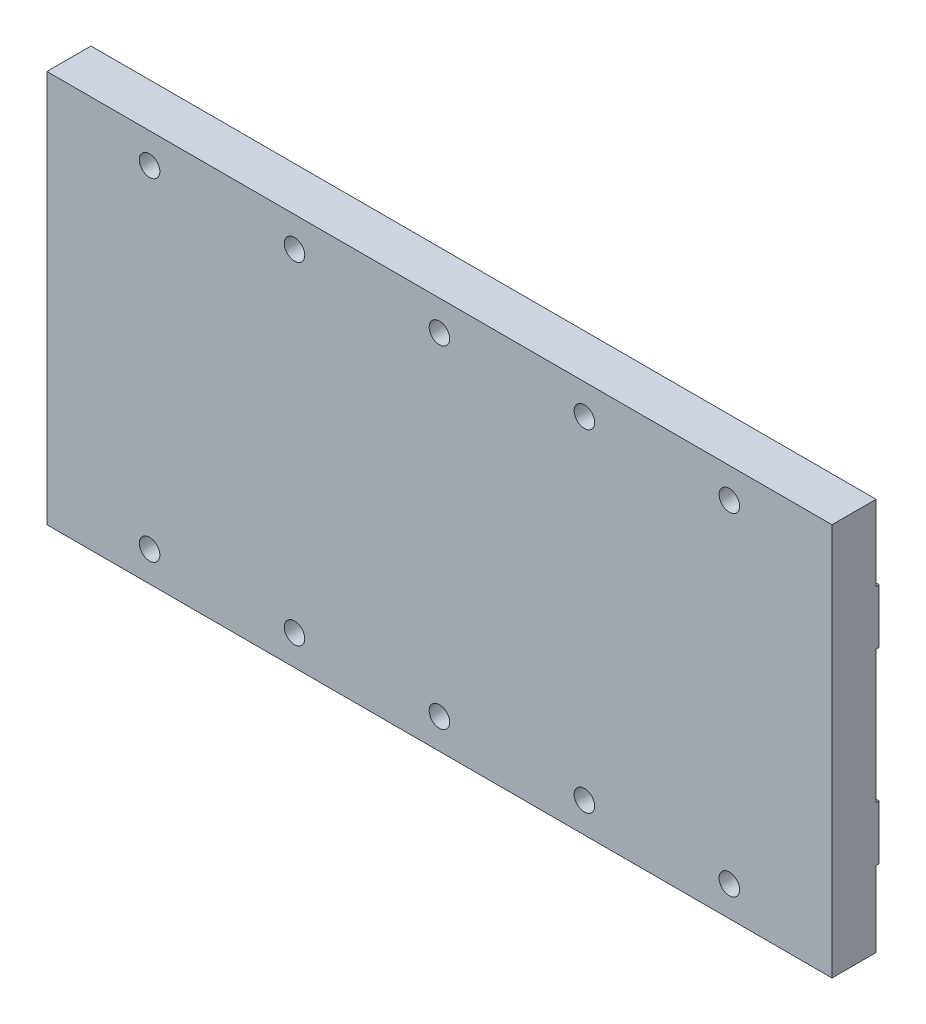
from build123d import *

# Parameters (mm, degrees)
ESQUISSE1_W             = 130
ESQUISSE1_H             = 65
ESQUISSE1_R             = 1.3
BOSS_EXTRU_1_DEPTH      = 7.8
ESQUISSE2_W             = 130
ESQUISSE2_H             = 12.5
ESQUISSE2_H_2           = 22
ENL_V_MAT_EXTRU_1_DEPTH = 0.5
D_GAGEMENT_M3_D         = 3.4
D_GAGEMENT_M3_DEPTH     = 6.978536948
D_GAGEMENT_M3_TIP       = 1.021463052


with BuildPart() as part:
    # Esquisse1 → Boss.-Extru.1 (new body)
    with BuildSketch(Plane.XY):
        with Locations((65, 32.5)):
            Rectangle(ESQUISSE1_W, ESQUISSE1_H)
        with Locations((113, 5)):
            Circle(ESQUISSE1_R, mode=Mode.SUBTRACT)
        with Locations((89, 5)):
            Circle(ESQUISSE1_R, mode=Mode.SUBTRACT)
        with Locations((65, 5)):
            Circle(ESQUISSE1_R, mode=Mode.SUBTRACT)
        with Locations((41, 5)):
            Circle(ESQUISSE1_R, mode=Mode.SUBTRACT)
        with Locations((17, 5)):
            Circle(ESQUISSE1_R, mode=Mode.SUBTRACT)
        with Locations((113, 60)):
            Circle(ESQUISSE1_R, mode=Mode.SUBTRACT)
        with Locations((89, 60)):
            Circle(ESQUISSE1_R, mode=Mode.SUBTRACT)
        with Locations((65, 60)):
            Circle(ESQUISSE1_R, mode=Mode.SUBTRACT)
        with Locations((41, 60)):
            Circle(ESQUISSE1_R, mode=Mode.SUBTRACT)
        with Locations((17, 60)):
            Circle(ESQUISSE1_R, mode=Mode.SUBTRACT)
    extrude(amount=BOSS_EXTRU_1_DEPTH)

    # Esquisse2 → Enlèv. mat.-Extru.1 (cut)
    with BuildSketch(Plane(origin=(0, 0, 0), x_dir=(-1, 0, 0), z_dir=(0, 0, -1))):
        with Locations((-65, 58.75)):
            Rectangle(ESQUISSE2_W, ESQUISSE2_H)
        with Locations((-65, 6.25)):
            Rectangle(ESQUISSE2_W, ESQUISSE2_H)
        with Locations((-65, 32.5)):
            Rectangle(ESQUISSE2_W, ESQUISSE2_H_2)
    extrude(amount=-ENL_V_MAT_EXTRU_1_DEPTH, mode=Mode.SUBTRACT)

    # Dégagement M3
    with Locations(Plane.XY.offset(7.8)):
        with Locations((17, 60), (41, 60), (65, 60), (89, 60), (113, 60), (113, 5), (89, 5), (65, 5), (41, 5), (17, 5)):
            Hole(D_GAGEMENT_M3_D / 2, depth=D_GAGEMENT_M3_DEPTH)
            with Locations((0, 0, -(D_GAGEMENT_M3_DEPTH + D_GAGEMENT_M3_TIP / 2))):  # 118° drill point
                Cone(0, D_GAGEMENT_M3_D / 2, D_GAGEMENT_M3_TIP, mode=Mode.SUBTRACT)


solid = part.part
